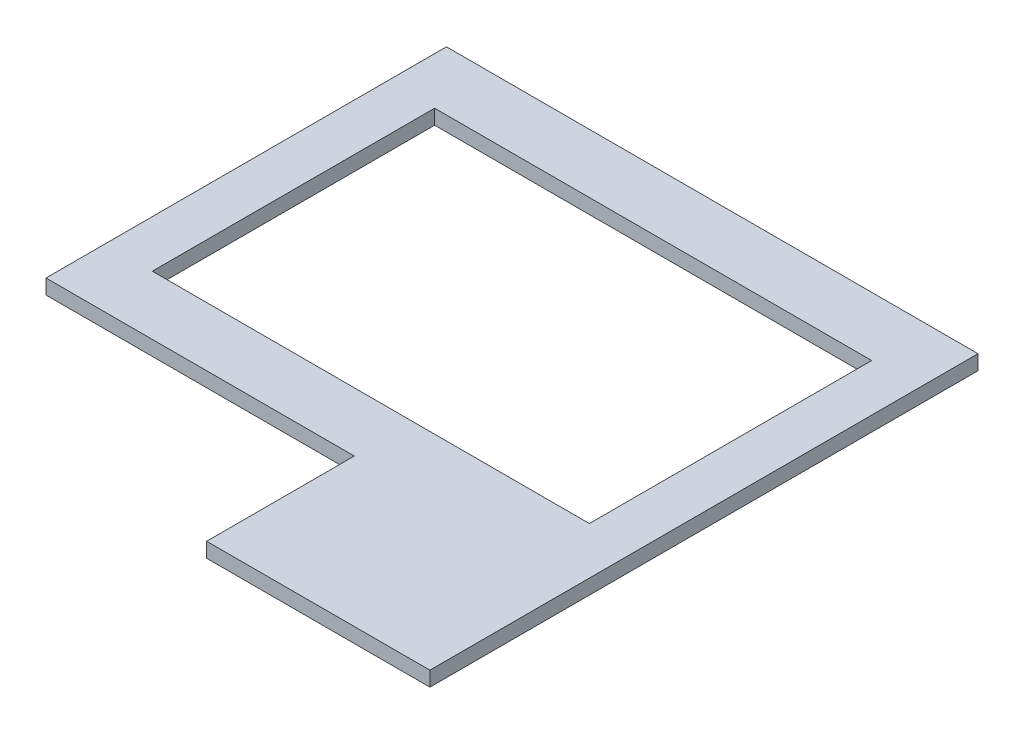
from build123d import *

# Parameters (mm, degrees)
SKETCH1_W           = 571.5
SKETCH1_H           = 430.53
SKETCH1_W_2         = 469.9
SKETCH1_H_2         = 303.53
BOSS_EXTRUDE1_DEPTH = 15.875
SKETCH2_W           = 240.03
SKETCH2_H           = 15.875
BOSS_EXTRUDE2_DEPTH = 158.75


with BuildPart() as part:
    # Sketch1 → Boss-Extrude1 (new body)
    with BuildSketch(Plane(origin=(0, 0, 0), x_dir=(1, 0, 0), z_dir=(0, 1, 0))):
        with Locations((285.75, 215.265)):
            Rectangle(SKETCH1_W, SKETCH1_H)
        with Locations((285.75, 215.265)):
            Rectangle(SKETCH1_W_2, SKETCH1_H_2, mode=Mode.SUBTRACT)
    extrude(amount=BOSS_EXTRUDE1_DEPTH)

    # Sketch2 → Boss-Extrude2 (add)
    with BuildSketch(Plane.XY):
        with Locations((451.485, 7.9375)):
            Rectangle(SKETCH2_W, SKETCH2_H)
    extrude(amount=BOSS_EXTRUDE2_DEPTH)


solid = part.part
